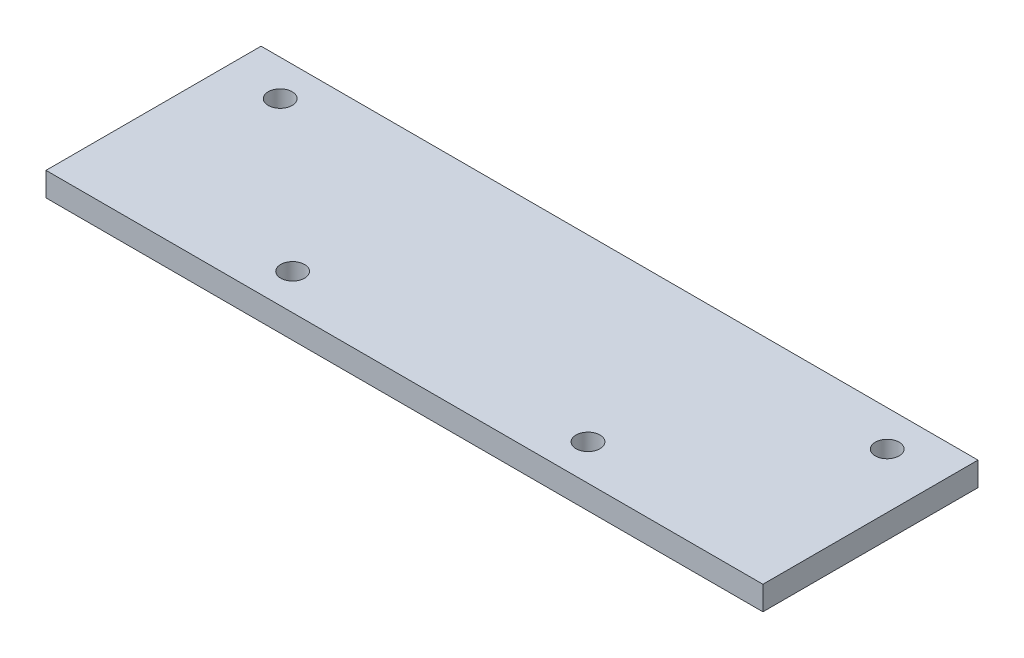
from build123d import *

# Parameters (mm, degrees)
SKETCH1_W           = 190.5
SKETCH1_H           = 57.15
BOSS_EXTRUDE1_DEPTH = 6.35
SKETCH3_R           = 3.175
CUT_EXTRUDE2_DEPTH  = 7.35


with BuildPart() as part:
    # Sketch1 → Boss-Extrude1 (new body)
    with BuildSketch(Plane(origin=(0, 0, 0), x_dir=(1, 0, 0), z_dir=(0, 1, 0))):
        Rectangle(SKETCH1_W, SKETCH1_H)
    extrude(amount=BOSS_EXTRUDE1_DEPTH)

    # Sketch3 → Cut-Extrude2 (cut, through all)
    with BuildSketch(Plane.XZ):
        with Locations((-80.645, -19.05)):
            Circle(SKETCH3_R)
        with Locations((-39.243, 19.05)):
            Circle(SKETCH3_R)
    cut_extrude2 = extrude(amount=-CUT_EXTRUDE2_DEPTH, mode=Mode.SUBTRACT)

    # Mirror1: Cut-Extrude2 across plane
    add(cut_extrude2.mirror(Plane(origin=(0, 0, 0), x_dir=(0, 0, 1), z_dir=(1, 0, 0))), mode=Mode.SUBTRACT)


solid = part.part
